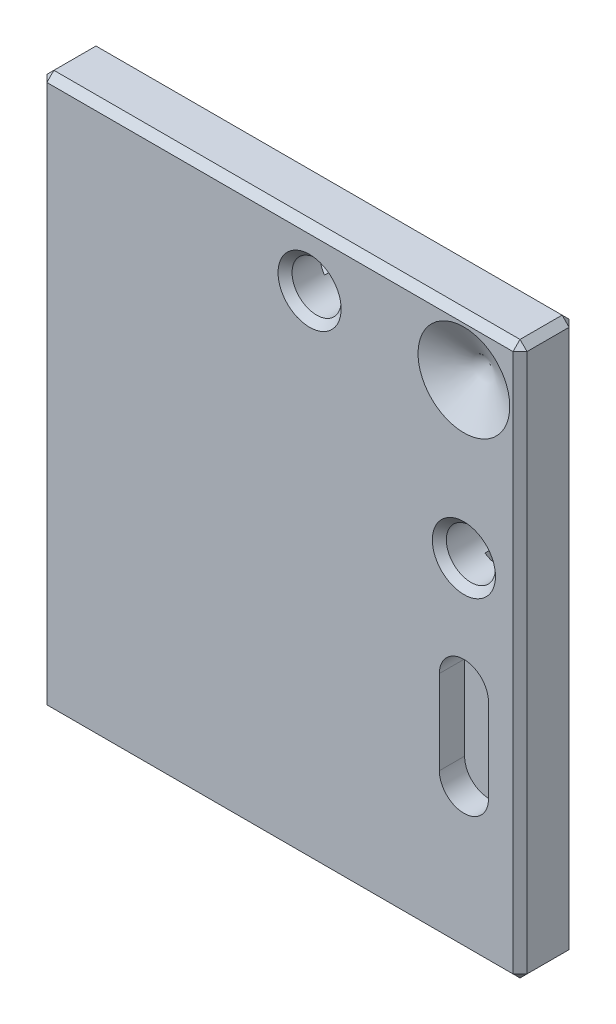
from build123d import *

# Parameters (mm, degrees)
SKICA1_W                 = 34.225
SKICA1_H                 = 39.4198
P_IDAT_VYSUNUT_M1_DEPTH  = 0.5
SKICA2_W                 = 34.225
SKICA2_H                 = 39.4198
P_IDAT_VYSUNUT_M2_DEPTH  = 3.5
ODEBRAT_VYSUNUT_M1_DEPTH = 1.8
SKICA10_R                = 4
ODEBRAT_VYSUNUT_M2_DEPTH = 0.3
F_3_5_3_5_PR_M_R_D_RY2_D = 3.5
ODEBRAT_VYSUNUT_M3_DEPTH = 1.5
ZKOSEN_1_SIZE            = 0.5
ZKOSEN_2_SIZE            = 0.5


with BuildPart() as part:
    # Skica1 → Přidat vysunutím1 (new body)
    with BuildSketch(Plane.XY):
        with Locations((0, 8.35)):
            Rectangle(SKICA1_W, SKICA1_H)
        with BuildLine():
            add(Edge.make_bspline(
                [(0, 22.3099), (-0.246563065, 22.3099), (-0.728122288, 22.288848257), (-1.777632638, 22.145587032), (-3.184972708, 21.743129564), (-5.004743408, 20.777166583), (-7.484278794, 18.688737501), (-9.783532683, 15.143578871), (-11.124914139, 10.319965431), (-11.48129293, 6.35), (-11.124914139, 2.380034569), (-9.783532683, -2.443578871), (-7.484278794, -5.988737501), (-5.004743408, -8.077166583), (-3.184972708, -9.043129564), (-1.777632638, -9.445587032), (-0.728122288, -9.588848257), (-0.246563065, -9.6099), (0, -9.6099)],
                knots=[3.141592654, 3.141592654, 3.141592654, 3.141592654, 3.239767424, 3.337942194, 3.534291735, 3.730641276, 3.926990817, 4.319689899, 4.51603944, 4.71238898, 4.908738521, 5.105088062, 5.497787144, 5.694136685, 5.890486225, 6.086835766, 6.185010537, 6.283185307, 6.283185307, 6.283185307, 6.283185307], degree=3))
            add(Edge.make_bspline(
                [(0, -9.6099), (0.246563065, -9.6099), (0.728122288, -9.588848257), (1.777632638, -9.445587032), (3.184972708, -9.043129564), (5.004743408, -8.077166583), (7.484278794, -5.988737501), (9.783532683, -2.443578871), (11.124914139, 2.380034569), (11.48129293, 6.35), (11.124914139, 10.319965431), (9.783532683, 15.143578871), (7.484278794, 18.688737501), (5.004743408, 20.777166583), (3.184972708, 21.743129564), (1.777632638, 22.145587032), (0.728122288, 22.288848257), (0.246563065, 22.3099), (0, 22.3099)],
                knots=[0, 0, 0, 0, 0.09817477, 0.196349541, 0.392699082, 0.589048623, 0.785398163, 1.178097245, 1.374446786, 1.570796327, 1.767145868, 1.963495408, 2.35619449, 2.552544031, 2.748893572, 2.945243113, 3.043417883, 3.141592654, 3.141592654, 3.141592654, 3.141592654], degree=3))
        make_face(mode=Mode.SUBTRACT)
    extrude(amount=-P_IDAT_VYSUNUT_M1_DEPTH)

    # Skica2 → Přidat vysunutím2 (add)
    with BuildSketch(Plane.XY):
        with Locations((0, 8.35)):
            Rectangle(SKICA2_W, SKICA2_H)
    extrude(amount=P_IDAT_VYSUNUT_M2_DEPTH)

    # Skica6 → Odebrat vysunutím1 (cut)
    with BuildSketch(Plane.XY.offset(3.5)):
        with BuildLine():
            Line((11.3625, -0.9401), (11.3625, 5.0599))
            ThreePointArc((11.3625, 5.0599), (13.1125, 6.8099), (14.8625, 5.0599))
            Line((14.8625, 5.0599), (14.8625, -0.9401))
            ThreePointArc((14.8625, -0.9401), (13.1125, -2.6901), (11.3625, -0.9401))
        make_face()
    extrude(amount=-ODEBRAT_VYSUNUT_M1_DEPTH, mode=Mode.SUBTRACT)

    # Skica9 → Odebrat rotací1 (revolve, cut)
    with BuildSketch(Plane(origin=(13.1125, 0, 0), x_dir=(0, -1, 0), z_dir=(-1, 0, 0))):
        Polygon((-27.327849192, 3.5), (-24.0599, 3.5), (-24.0599, 1.613248654), align=None)
    revolve(axis=Axis((13.1125, 24.0599, 3.5), (0, 0, -1)), mode=Mode.SUBTRACT)

    # Skica10 → Odebrat vysunutím2 (cut)
    with BuildSketch(Plane(origin=(0, 0, 0), x_dir=(-1, 0, 0), z_dir=(0, 0, -1))):
        with Locations((0, 6.35)):
            Circle(SKICA10_R)
    extrude(amount=-ODEBRAT_VYSUNUT_M2_DEPTH, mode=Mode.SUBTRACT)

    # Ø3.5 (3.5) průměr díry2 (through all)
    with Locations(Plane(origin=(2.1125, 24.0599, 3.5), x_dir=(1, 0, 0), z_dir=(0, 0, 1))):
        with Locations((0, 0), (11, -11)):
            Hole(F_3_5_3_5_PR_M_R_D_RY2_D / 2)

    # Skica16 → Odebrat vysunutím3 (cut)
    with BuildSketch(Plane(origin=(0, 0, -0.5), x_dir=(-1, 0, 0), z_dir=(0, 0, -1))):
        with BuildLine():
            Line((0.3875, 23.0599), (-4.6125, 23.0599))
            ThreePointArc((-4.6125, 23.0599), (-5.6125, 24.0599), (-4.6125, 25.0599))
            Line((-4.6125, 25.0599), (0.3875, 25.0599))
            ThreePointArc((0.3875, 25.0599), (1.3875, 24.0599), (0.3875, 23.0599))
        make_face()
        with BuildLine():
            Line((-14.1125, 10.5599), (-14.1125, 15.5599))
            ThreePointArc((-14.1125, 15.5599), (-13.1125, 16.5599), (-12.1125, 15.5599))
            Line((-12.1125, 15.5599), (-12.1125, 10.5599))
            ThreePointArc((-12.1125, 10.5599), (-13.1125, 9.5599), (-14.1125, 10.5599))
        make_face()
    extrude(amount=-ODEBRAT_VYSUNUT_M3_DEPTH, mode=Mode.SUBTRACT)

    # Zkosení1
    zkosen_1_edges = [part.edges().sort_by_distance(p)[0] for p in [
        (17.1125, 8.35, -0.5),
        (0, 28.0599, -0.5),
        (-17.1125, 8.35, 3.5),
        (0, -11.3599, 3.5),
        (17.1125, 8.35, 3.5),
        (0, 28.0599, 3.5),
        (-17.1125, 8.35, -0.5),
        (-17.1125, 28.0599, 1.5),
        (17.1125, 28.0599, 1.5),
        (17.1125, -11.3599, 1.5),
        (-17.1125, -11.3599, 1.5),
        (0, -11.3599, -0.5),
    ]]
    chamfer(zkosen_1_edges, length=ZKOSEN_1_SIZE)

    # Zkosení2
    zkosen_2_edges = [part.edges().sort_by_distance(p)[0] for p in [
        (14.8625, 13.0599, 3.5),
        (3.8625, 24.0599, 3.5),
    ]]
    chamfer(zkosen_2_edges, length=ZKOSEN_2_SIZE)


solid = part.part
